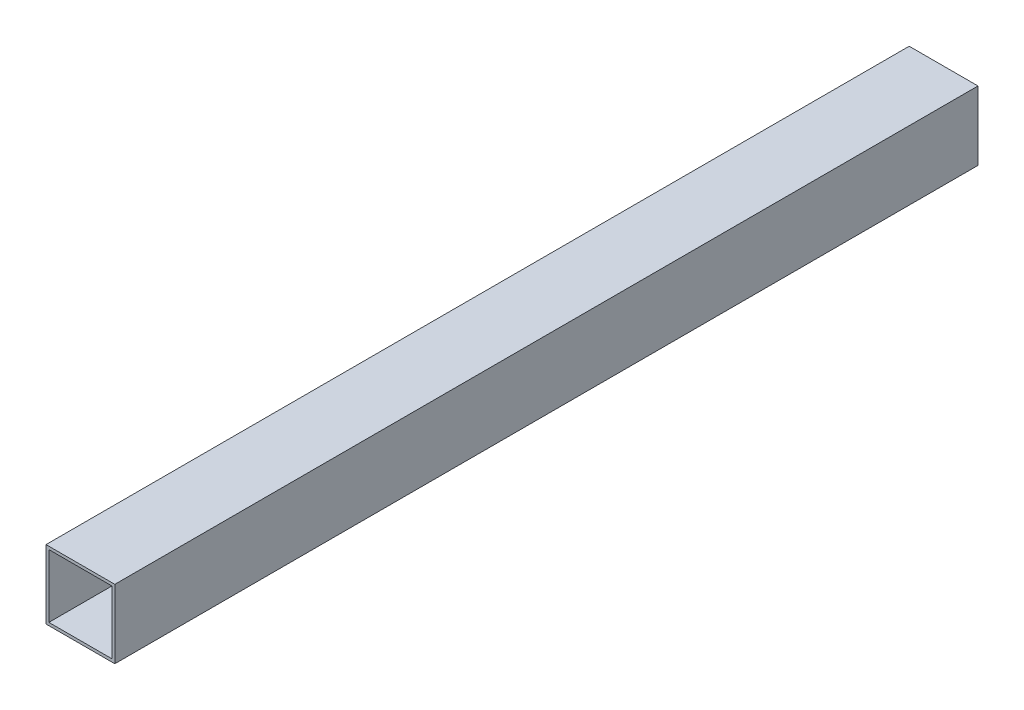
from build123d import *

# Parameters (mm, degrees)
SKETCH1_W           = 72.898
SKETCH1_H           = 72.898
SKETCH1_W_2         = 66.802
SKETCH1_H_2         = 66.802
BOSS_EXTRUDE1_DEPTH = 914.4


with BuildPart() as part:
    # Sketch1 → Boss-Extrude1 (new body)
    with BuildSketch(Plane.XY):
        Rectangle(SKETCH1_W, SKETCH1_H)
        Rectangle(SKETCH1_W_2, SKETCH1_H_2, mode=Mode.SUBTRACT)
    extrude(amount=BOSS_EXTRUDE1_DEPTH)


solid = part.part
